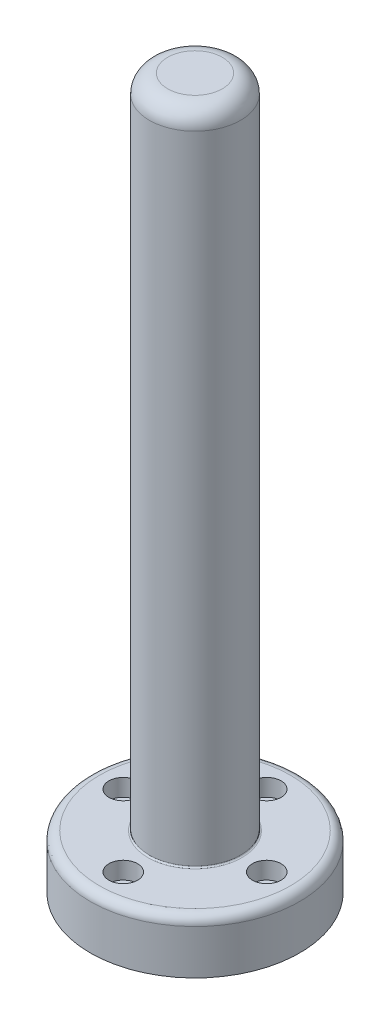
from build123d import *

# Parameters (mm, degrees)
SKETCH1_R               = 36.5125
SKETCH1_R_2             = 31.75
BOSS_EXTRUDE1_DEPTH     = 6.35
BOSS_EXTRUDE2_START     = 12.35
SKETCH1_2_R             = 36.5125
BOSS_EXTRUDE2_DEPTH     = 12.35
CUT_EXTRUDE1_DEPTH      = 55.918260283
CUT_EXTRUDE1_DEPTH_BACK = 55.918260283
SKETCH2_R               = 3.3
SKETCH3_R               = 15.875
BOSS_EXTRUDE3_DEPTH     = 228.6
CUT_EXTRUDE2_DEPTH      = 235.359308141
CUT_EXTRUDE2_DEPTH_BACK = 6
SKETCH4_R               = 5
FILLET2_R               = 0.508
FILLET3_R               = 3.175
SKETCH5_R               = 9.525
CUT_EXTRUDE3_DEPTH      = 222.25
FILLET4_R               = 6.35
BOSS_EXTRUDE4_START     = -6.35
SKETCH6_R               = 15.875
BOSS_EXTRUDE4_DEPTH     = 6.35
FILLET5_R               = 6.35


with BuildPart() as part:
    # Sketch1 → Boss-Extrude1 (new body)
    with BuildSketch(Plane(origin=(0, 0, 0), x_dir=(1, 0, 0), z_dir=(0, 1, 0))):
        Circle(SKETCH1_R)
        Circle(SKETCH1_R_2, mode=Mode.SUBTRACT)
    extrude(amount=-BOSS_EXTRUDE1_DEPTH)

    # Sketch1_2 → Boss-Extrude2 (add)
    with BuildSketch(Plane(origin=(0, 0, 0), x_dir=(1, 0, 0), z_dir=(0, 1, 0)).offset(BOSS_EXTRUDE2_START)):
        Circle(SKETCH1_2_R)
    extrude(amount=-BOSS_EXTRUDE2_DEPTH)

    # Sketch2 → Cut-Extrude1 (cut, two sides: drawn at the far end of the back side and taken through both)
    with BuildSketch(Plane(origin=(0, 12.35, 0), x_dir=(1, 0, 0), z_dir=(0, 1, 0)).offset(-CUT_EXTRUDE1_DEPTH_BACK)):
        with Locations((0, 25)):
            Circle(SKETCH2_R)
        with Locations((25, 0)):
            Circle(SKETCH2_R)
        with Locations((0, -25)):
            Circle(SKETCH2_R)
        with Locations((-25, 0)):
            Circle(SKETCH2_R)
    extrude(amount=CUT_EXTRUDE1_DEPTH + CUT_EXTRUDE1_DEPTH_BACK, mode=Mode.SUBTRACT)

    # Sketch3 → Boss-Extrude3 (add)
    with BuildSketch(Plane(origin=(0, 12.35, 0), x_dir=(1, 0, 0), z_dir=(0, 1, 0))):
        Circle(SKETCH3_R)
    extrude(amount=BOSS_EXTRUDE3_DEPTH)

    # Sketch4 → Cut-Extrude2 (cut, two sides: drawn at the far end of the back side and taken through both)
    with BuildSketch(Plane(origin=(0, 12.35, 0), x_dir=(1, 0, 0), z_dir=(0, 1, 0)).offset(-CUT_EXTRUDE2_DEPTH_BACK)):
        with Locations((-25, 0)):
            Circle(SKETCH4_R)
        with Locations((0, 25)):
            Circle(SKETCH4_R)
        with Locations((25, 0)):
            Circle(SKETCH4_R)
        with Locations((0, -25)):
            Circle(SKETCH4_R)
    extrude(amount=CUT_EXTRUDE2_DEPTH + CUT_EXTRUDE2_DEPTH_BACK, mode=Mode.SUBTRACT)

    # Fillet2
    fillet2_edges = [part.edges().sort_by_distance(p)[0] for p in [
        (-15.875, 12.35, 0),
    ]]
    fillet(fillet2_edges, radius=FILLET2_R)

    # Fillet3
    fillet3_edges = [part.edges().sort_by_distance(p)[0] for p in [
        (-36.5125, 12.35, 0),
    ]]
    fillet(fillet3_edges, radius=FILLET3_R)

    # Sketch5 → Cut-Extrude3 (cut)
    with BuildSketch(Plane(origin=(0, 240.95, 0), x_dir=(1, 0, 0), z_dir=(0, 1, 0))):
        Circle(SKETCH5_R)
    extrude(amount=-CUT_EXTRUDE3_DEPTH, mode=Mode.SUBTRACT)

    # Fillet4
    fillet4_edges = [part.edges().sort_by_distance(p)[0] for p in [
        (-9.525, 18.7, 0),
    ]]
    fillet(fillet4_edges, radius=FILLET4_R)

    # Sketch6 → Boss-Extrude4 (add)
    with BuildSketch(Plane(origin=(0, 240.95, 0), x_dir=(1, 0, 0), z_dir=(0, 1, 0)).offset(BOSS_EXTRUDE4_START)):
        Circle(SKETCH6_R)
    extrude(amount=BOSS_EXTRUDE4_DEPTH)

    # Fillet5
    fillet5_edges = [part.edges().sort_by_distance(p)[0] for p in [
        (-15.875, 240.95, 0),
        (-9.525, 234.6, 0),
    ]]
    fillet(fillet5_edges, radius=FILLET5_R)


solid = part.part
